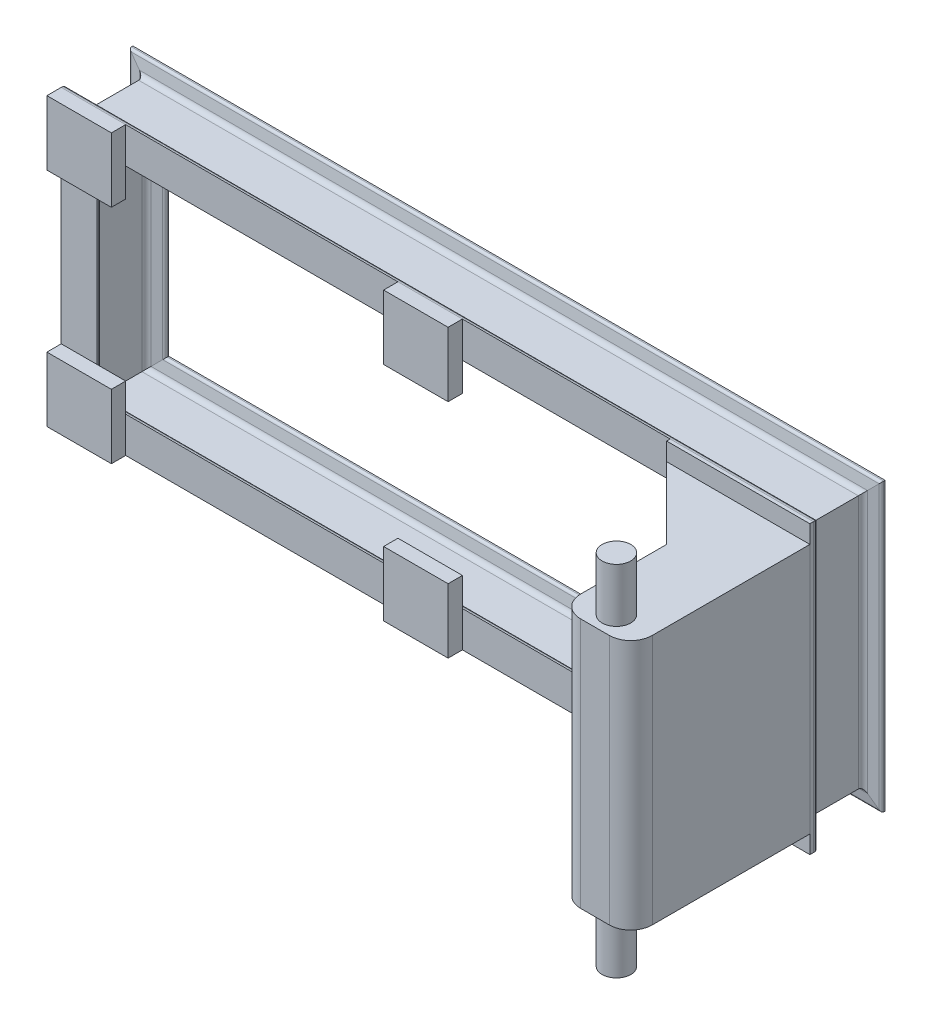
from build123d import *

# Parameters (mm, degrees)
SB_BEAM_CONFIGURED_100_X_8_1_DEPTH      = 1056.901699437
SB_BEAM_CONFIGURED_100_X_8_1_DEPTH_BACK = 56.901699437
SB_BEAM_CONFIGURED_100_X_8_1_2_DEPTH    = 463.803398875
SB_BEAM_CONFIGURED_100_X_8_1_3_DEPTH    = 1113.803398875
SB_BEAM_CONFIGURED_100_X_8_1_4_DEPTH    = 463.803398875
SKETCH17_W                              = 90
SKETCH17_H                              = 90
BOSS_EXTRUDE1_DEPTH                     = 20
BOSS_EXTRUDE1_2_DEPTH                   = 20
BOSS_EXTRUDE1_3_DEPTH                   = 20
BOSS_EXTRUDE1_4_DEPTH                   = 20
SKETCH18_W                              = 200
SKETCH18_H                              = 400
BOSS_EXTRUDE2_DEPTH                     = 5
BOSS_EXTRUDE3_DEPTH                     = 175
SKETCH21_R                              = 20
BOSS_EXTRUDE4_DEPTH                     = 250
FILLET1_R                               = 30


with BuildPart() as part:
    # Sketch16 → Sb beam - configured 100 X 8(1) (new, two sides)
    with BuildSketch(Plane(origin=(500, 175, 0), x_dir=(0, -1, 0), z_dir=(-1, 0, 0))) as sb_beam_configured_100_x_8_1_sk:
        with BuildLine():
            Line((-25, -50), (-25, -48.060671023))
            ThreePointArc((-25, -48.060671023), (-24.17058332, -45.798374682), (-22.075437296, -44.608299096))
            Line((-22.075437296, -44.608299096), (-8.099125408, -42.278743853))
            ThreePointArc((-8.099125408, -42.278743853), (-3.90883336, -39.898592681), (-2.25, -35.374))
            Line((-2.25, -35.374), (-2.25, 35.374))
            ThreePointArc((-2.25, 35.374), (-3.90883336, 39.898592681), (-8.099125408, 42.278743853))
            Line((-8.099125408, 42.278743853), (-22.075437296, 44.608299096))
            ThreePointArc((-22.075437296, 44.608299096), (-24.17058332, 45.798374682), (-25, 48.060671023))
            Line((-25, 48.060671023), (-25, 50))
            Line((-25, 50), (25, 50))
            Line((25, 50), (25, 48.060671023))
            ThreePointArc((25, 48.060671023), (24.17058332, 45.798374682), (22.075437296, 44.608299096))
            Line((22.075437296, 44.608299096), (8.099125408, 42.278743853))
            ThreePointArc((8.099125408, 42.278743853), (3.90883336, 39.898592681), (2.25, 35.374))
            Line((2.25, 35.374), (2.25, -35.374))
            ThreePointArc((2.25, -35.374), (3.90883336, -39.898592681), (8.099125408, -42.278743853))
            Line((8.099125408, -42.278743853), (22.075437296, -44.608299096))
            ThreePointArc((22.075437296, -44.608299096), (24.17058332, -45.798374682), (25, -48.060671023))
            Line((25, -48.060671023), (25, -50))
            Line((25, -50), (-25, -50))
        make_face()
    extrude(amount=SB_BEAM_CONFIGURED_100_X_8_1_DEPTH)
    extrude(sb_beam_configured_100_x_8_1_sk.sketch, amount=-SB_BEAM_CONFIGURED_100_X_8_1_DEPTH_BACK)

    # Sb beam - configured 100 X 8(1) mitre 1
    split(bisect_by=Plane(origin=(500, 175, 0), x_dir=(-0.707106781, -0.707106781, 0), z_dir=(-0.707106781, 0.707106781, 0)), keep=Keep.TOP)

    # Sb beam - configured 100 X 8(1) mitre 2
    split(bisect_by=Plane(origin=(-500, 175, 0), x_dir=(-0.707106781, 0.707106781, 0), z_dir=(0.707106781, 0.707106781, 0)), keep=Keep.TOP)


with BuildPart() as body_2:
    # Sketch16 on segment 2 (carried to segment 2) → Sb beam - configured 100 X 8_1 2 (new body)
    with BuildSketch(Plane(origin=(-500, 231.901699437, 0), x_dir=(1, 0, 0), z_dir=(0, -1, 0))):
        with BuildLine():
            Line((-25, -50), (-25, -48.060671023))
            ThreePointArc((-25, -48.060671023), (-24.17058332, -45.798374682), (-22.075437296, -44.608299096))
            Line((-22.075437296, -44.608299096), (-8.099125408, -42.278743853))
            ThreePointArc((-8.099125408, -42.278743853), (-3.90883336, -39.898592681), (-2.25, -35.374))
            Line((-2.25, -35.374), (-2.25, 35.374))
            ThreePointArc((-2.25, 35.374), (-3.90883336, 39.898592681), (-8.099125408, 42.278743853))
            Line((-8.099125408, 42.278743853), (-22.075437296, 44.608299096))
            ThreePointArc((-22.075437296, 44.608299096), (-24.17058332, 45.798374682), (-25, 48.060671023))
            Line((-25, 48.060671023), (-25, 50))
            Line((-25, 50), (25, 50))
            Line((25, 50), (25, 48.060671023))
            ThreePointArc((25, 48.060671023), (24.17058332, 45.798374682), (22.075437296, 44.608299096))
            Line((22.075437296, 44.608299096), (8.099125408, 42.278743853))
            ThreePointArc((8.099125408, 42.278743853), (3.90883336, 39.898592681), (2.25, 35.374))
            Line((2.25, 35.374), (2.25, -35.374))
            ThreePointArc((2.25, -35.374), (3.90883336, -39.898592681), (8.099125408, -42.278743853))
            Line((8.099125408, -42.278743853), (22.075437296, -44.608299096))
            ThreePointArc((22.075437296, -44.608299096), (24.17058332, -45.798374682), (25, -48.060671023))
            Line((25, -48.060671023), (25, -50))
            Line((25, -50), (-25, -50))
        make_face()
    extrude(amount=SB_BEAM_CONFIGURED_100_X_8_1_2_DEPTH)

    # Sb beam - configured 100 X 8_1 2 mitre 1
    split(bisect_by=Plane(origin=(-500, 175, 0), x_dir=(0.707106781, -0.707106781, 0), z_dir=(-0.707106781, -0.707106781, 0)), keep=Keep.TOP)

    # Sb beam - configured 100 X 8_1 2 mitre 2
    split(bisect_by=Plane(origin=(-500, -175, 0), x_dir=(-0.707106781, -0.707106781, 0), z_dir=(-0.707106781, 0.707106781, 0)), keep=Keep.TOP)


with BuildPart() as body_3:
    # Sketch16 on segment 3 (carried to segment 3) → Sb beam - configured 100 X 8_1 3 (new body)
    with BuildSketch(Plane(origin=(-556.901699437, -175, 0), x_dir=(0, 1, 0), z_dir=(1, 0, 0))):
        with BuildLine():
            Line((-25, -50), (-25, -48.060671023))
            ThreePointArc((-25, -48.060671023), (-24.17058332, -45.798374682), (-22.075437296, -44.608299096))
            Line((-22.075437296, -44.608299096), (-8.099125408, -42.278743853))
            ThreePointArc((-8.099125408, -42.278743853), (-3.90883336, -39.898592681), (-2.25, -35.374))
            Line((-2.25, -35.374), (-2.25, 35.374))
            ThreePointArc((-2.25, 35.374), (-3.90883336, 39.898592681), (-8.099125408, 42.278743853))
            Line((-8.099125408, 42.278743853), (-22.075437296, 44.608299096))
            ThreePointArc((-22.075437296, 44.608299096), (-24.17058332, 45.798374682), (-25, 48.060671023))
            Line((-25, 48.060671023), (-25, 50))
            Line((-25, 50), (25, 50))
            Line((25, 50), (25, 48.060671023))
            ThreePointArc((25, 48.060671023), (24.17058332, 45.798374682), (22.075437296, 44.608299096))
            Line((22.075437296, 44.608299096), (8.099125408, 42.278743853))
            ThreePointArc((8.099125408, 42.278743853), (3.90883336, 39.898592681), (2.25, 35.374))
            Line((2.25, 35.374), (2.25, -35.374))
            ThreePointArc((2.25, -35.374), (3.90883336, -39.898592681), (8.099125408, -42.278743853))
            Line((8.099125408, -42.278743853), (22.075437296, -44.608299096))
            ThreePointArc((22.075437296, -44.608299096), (24.17058332, -45.798374682), (25, -48.060671023))
            Line((25, -48.060671023), (25, -50))
            Line((25, -50), (-25, -50))
        make_face()
    extrude(amount=SB_BEAM_CONFIGURED_100_X_8_1_3_DEPTH)

    # Sb beam - configured 100 X 8_1 3 mitre 1
    split(bisect_by=Plane(origin=(500, -175, 0), x_dir=(0.707106781, -0.707106781, 0), z_dir=(-0.707106781, -0.707106781, 0)), keep=Keep.TOP)

    # Sb beam - configured 100 X 8_1 3 mitre 2
    split(bisect_by=Plane(origin=(-500, -175, 0), x_dir=(0.707106781, 0.707106781, 0), z_dir=(0.707106781, -0.707106781, 0)), keep=Keep.TOP)


with BuildPart() as body_4:
    # Sketch16 on segment 4 (carried to segment 4) → Sb beam - configured 100 X 8_1 4 (new body)
    with BuildSketch(Plane(origin=(500, -231.901699437, 0), x_dir=(-1, 0, 0), z_dir=(0, 1, 0))):
        with BuildLine():
            Line((-25, -50), (-25, -48.060671023))
            ThreePointArc((-25, -48.060671023), (-24.17058332, -45.798374682), (-22.075437296, -44.608299096))
            Line((-22.075437296, -44.608299096), (-8.099125408, -42.278743853))
            ThreePointArc((-8.099125408, -42.278743853), (-3.90883336, -39.898592681), (-2.25, -35.374))
            Line((-2.25, -35.374), (-2.25, 35.374))
            ThreePointArc((-2.25, 35.374), (-3.90883336, 39.898592681), (-8.099125408, 42.278743853))
            Line((-8.099125408, 42.278743853), (-22.075437296, 44.608299096))
            ThreePointArc((-22.075437296, 44.608299096), (-24.17058332, 45.798374682), (-25, 48.060671023))
            Line((-25, 48.060671023), (-25, 50))
            Line((-25, 50), (25, 50))
            Line((25, 50), (25, 48.060671023))
            ThreePointArc((25, 48.060671023), (24.17058332, 45.798374682), (22.075437296, 44.608299096))
            Line((22.075437296, 44.608299096), (8.099125408, 42.278743853))
            ThreePointArc((8.099125408, 42.278743853), (3.90883336, 39.898592681), (2.25, 35.374))
            Line((2.25, 35.374), (2.25, -35.374))
            ThreePointArc((2.25, -35.374), (3.90883336, -39.898592681), (8.099125408, -42.278743853))
            Line((8.099125408, -42.278743853), (22.075437296, -44.608299096))
            ThreePointArc((22.075437296, -44.608299096), (24.17058332, -45.798374682), (25, -48.060671023))
            Line((25, -48.060671023), (25, -50))
            Line((25, -50), (-25, -50))
        make_face()
    extrude(amount=SB_BEAM_CONFIGURED_100_X_8_1_4_DEPTH)

    # Sb beam - configured 100 X 8_1 4 mitre 1
    split(bisect_by=Plane(origin=(500, 175, 0), x_dir=(0.707106781, 0.707106781, 0), z_dir=(0.707106781, -0.707106781, 0)), keep=Keep.TOP)

    # Sb beam - configured 100 X 8_1 4 mitre 2
    split(bisect_by=Plane(origin=(500, -175, 0), x_dir=(-0.707106781, 0.707106781, 0), z_dir=(0.707106781, 0.707106781, 0)), keep=Keep.TOP)


with BuildPart() as body_5:
    # Sketch17 → Boss-Extrude1 (new body)
    with BuildSketch(Plane.XY.offset(50)):
        with Locations((-480, 155)):
            Rectangle(SKETCH17_W, SKETCH17_H)
    extrude(amount=BOSS_EXTRUDE1_DEPTH)


with BuildPart() as body_6:
    # Sketch17 → Boss-Extrude1 2 (new body)
    with BuildSketch(Plane.XY.offset(50)):
        with Locations((-480, -155)):
            Rectangle(SKETCH17_W, SKETCH17_H)
    extrude(amount=BOSS_EXTRUDE1_2_DEPTH)


with BuildPart() as body_7:
    # Sketch17 → Boss-Extrude1 3 (new body)
    with BuildSketch(Plane.XY.offset(50)):
        with Locations((-10, 155)):
            Rectangle(SKETCH17_W, SKETCH17_H)
    extrude(amount=BOSS_EXTRUDE1_3_DEPTH)


with BuildPart() as body_8:
    # Sketch17 → Boss-Extrude1 4 (new body)
    with BuildSketch(Plane.XY.offset(50)):
        with Locations((-10, -155)):
            Rectangle(SKETCH17_W, SKETCH17_H)
    extrude(amount=BOSS_EXTRUDE1_4_DEPTH)


with BuildPart() as body_9:
    # Sketch18 → Boss-Extrude2 (new body)
    with BuildSketch(Plane.XY.offset(50)):
        with Locations((425, 0)):
            Rectangle(SKETCH18_W, SKETCH18_H)
    extrude(amount=BOSS_EXTRUDE2_DEPTH)


with BuildPart() as body_10:
    # Sketch20 → Boss-Extrude3 (new, symmetric)
    with BuildSketch(Plane(origin=(0, 0, 0), x_dir=(1, 0, 0), z_dir=(0, 1, 0))):
        Polygon((525, -55), (325, -55), (425, -155), (425, -305), (525, -305), align=None)
    extrude(amount=BOSS_EXTRUDE3_DEPTH, both=True)

    # Sketch21 → Boss-Extrude4 (add, symmetric)
    with BuildSketch(Plane(origin=(0, 0, 0), x_dir=(1, 0, 0), z_dir=(0, 1, 0))):
        with Locations(Location((475, -275, 0), (0, 0, 270))):
            Circle(SKETCH21_R)
    extrude(amount=BOSS_EXTRUDE4_DEPTH, both=True)

    # Fillet1
    fillet1_edges = [body_10.edges().sort_by_distance(p)[0] for p in [
        (525, 0, 305),
        (425, 0, 305),
    ]]
    fillet(fillet1_edges, radius=FILLET1_R)


solid = Compound([part.part, body_2.part, body_3.part, body_4.part, body_5.part, body_6.part, body_7.part, body_8.part, body_9.part, body_10.part])
